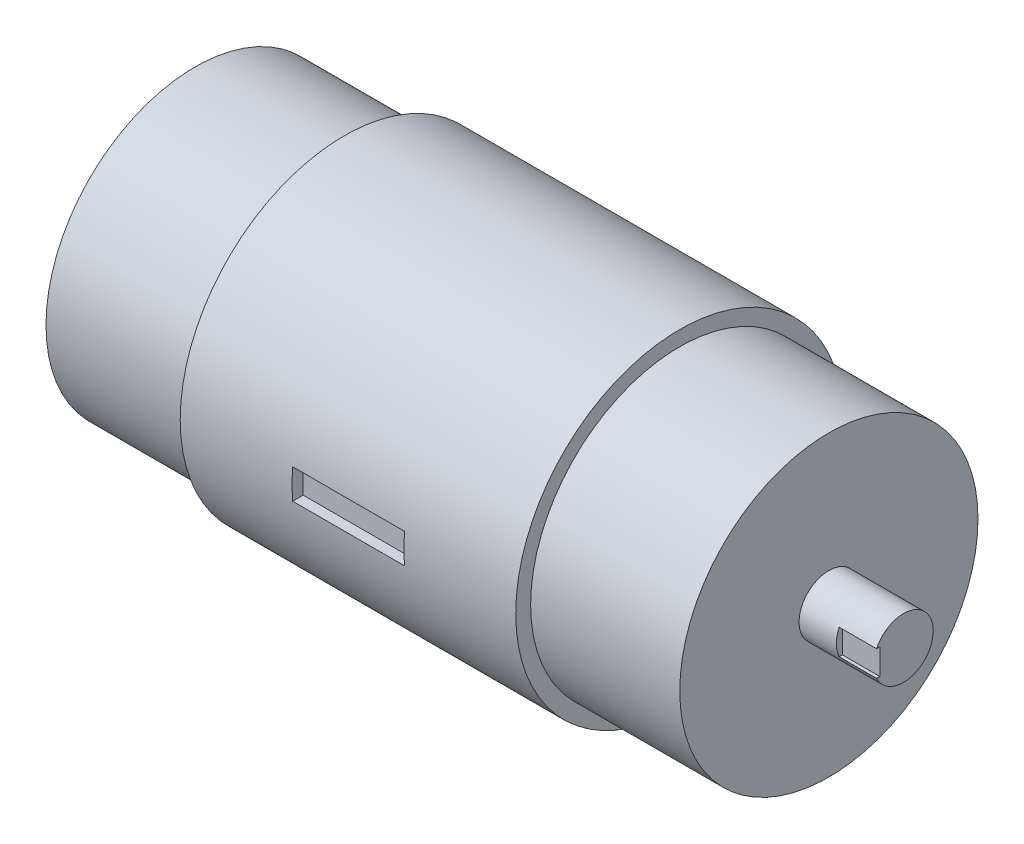
from build123d import *

# Parameters (mm, degrees)
SKETCH3_R           = 200
BOSS_EXTRUDE2_DEPTH = 200
SKETCH6_R           = 40
BOSS_EXTRUDE5_DEPTH = 100
CUT_EXTRUDE1_DEPTH  = 50
SKETCH5_R           = 220
BOSS_EXTRUDE6_DEPTH = 450
SKETCH9_R           = 200
BOSS_EXTRUDE7_DEPTH = 200
SKETCH10_W          = 150
SKETCH10_H          = 40
CUT_EXTRUDE2_DEPTH  = 15


with BuildPart() as part:
    # Sketch3 → Boss-Extrude2 (new body)
    with BuildSketch(Plane(origin=(800, 0, 0), x_dir=(0, 0, -1), z_dir=(1, 0, 0))):
        Circle(SKETCH3_R)
    extrude(amount=-BOSS_EXTRUDE2_DEPTH)

    # Sketch5 → Boss-Extrude6 (add)
    with BuildSketch(Plane(origin=(600, 0, 0), x_dir=(0, 0, -1), z_dir=(1, 0, 0))):
        Circle(SKETCH5_R)
    extrude(amount=-BOSS_EXTRUDE6_DEPTH)

    # Sketch9 → Boss-Extrude7 (add)
    with BuildSketch(Plane.ZY.offset(-150)):
        Circle(SKETCH9_R)
    extrude(amount=BOSS_EXTRUDE7_DEPTH)

    # Sketch10 → Cut-Extrude2 (cut)
    with BuildSketch(Plane(origin=(600, 0, 220), x_dir=(1, 0, 0), z_dir=(0, 0, 1))):
        with Locations((-225, 0)):
            Rectangle(SKETCH10_W, SKETCH10_H)
    extrude(amount=-CUT_EXTRUDE2_DEPTH, mode=Mode.SUBTRACT)


with BuildPart() as body_2:
    # Sketch6 → Boss-Extrude5 (new body)
    with BuildSketch(Plane(origin=(800, 0, 0), x_dir=(0, 0, -1), z_dir=(1, 0, 0))):
        Circle(SKETCH6_R)
    extrude(amount=BOSS_EXTRUDE5_DEPTH)

    # Sketch8 → Cut-Extrude1 (cut)
    with BuildSketch(Plane(origin=(900, 0, 0), x_dir=(0, 0, -1), z_dir=(1, 0, 0))):
        with BuildLine():
            Line((-36.119828524, 17.185982294), (-31.709283015, 17.185982294))
            Line((-31.709283015, 17.185982294), (-31.709283015, -17.185982294))
            Line((-31.709283015, -17.185982294), (-36.119828524, -17.185982294))
            ThreePointArc((-36.119828524, -17.185982294), (-40, 0), (-36.119828524, 17.185982294))
        make_face()
    extrude(amount=-CUT_EXTRUDE1_DEPTH, mode=Mode.SUBTRACT)


solid = Compound([part.part, body_2.part])
